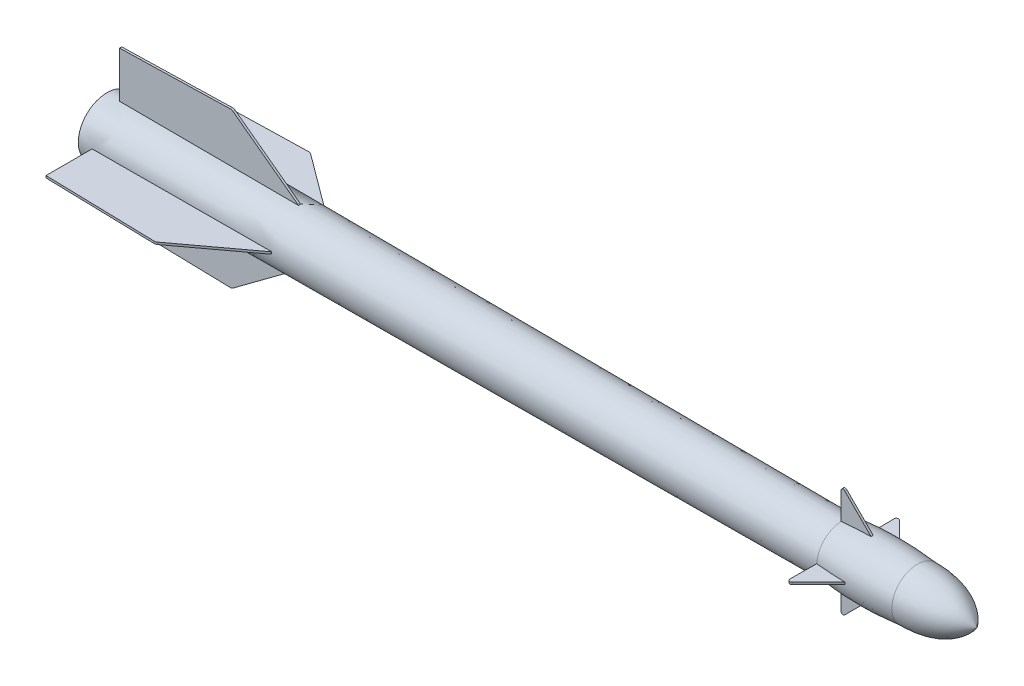
from build123d import *

# Parameters (mm, degrees)
BOSS_EXTRUDE8_DEPTH = 5
CIRPATTERN14_COUNT  = 4


with BuildPart() as part:
    # Sketch1 → Revolve2 (revolve)
    with BuildSketch(Plane.XY, mode=Mode.PRIVATE) as revolve2_sk:
        with BuildLine():
            Line((-11308.603422809, 18737.192157596), (-14752.957029779, 18751.87594239))
            Line((-14752.957029779, 18751.87594239), (-14752.957029779, 18617.692795252))
            Line((-14752.957029779, 18617.692795252), (-10678.442681077, 18617.692795252))
            add(Edge.make_bspline(
                [(-10678.442681077, 18617.692795252), (-10743.936723507, 18714.346501793), (-10855.803538483, 18738.002157903), (-10956.763854167, 18737.192157596)],
                knots=[0, 0, 0, 0, 1, 1, 1, 1], degree=3))
            add(Edge.make_bspline(
                [(-10956.763854167, 18737.192157596), (-11131.759366727, 18755.201630085), (-11308.603422809, 18737.192157596)],
                knots=[0, 0, 0, 1, 1, 1], degree=2))
        make_face()
    revolve(revolve2_sk.sketch.rotate(Axis((-10678.442681077, 18617.692795252, 0), (-1, 0, 0)), 90), axis=Axis((-10678.442681077, 18617.692795252, 0), (-1, 0, 0)))

    # Sketch3 (on Front Plane) → Boss-Extrude8 (add, symmetric)
    with BuildSketch(Plane.XY):
        with BuildLine():
            Line((-13854.314775163, 18751.130357924), (-14157.601672148, 18976.193937587))
            ThreePointArc((-14157.601672148, 18976.193937587), (-14163.477990114, 18979.198581722), (-14170.012281188, 18980.127042479))
            Line((-14170.012281188, 18980.127042479), (-14688.732210559, 18967.35855191))
            Line((-14688.732210559, 18967.35855191), (-14688.732210559, 18715.069519236))
            Line((-14688.732210559, 18715.069519236), (-13866.233225592, 18715.069519236))
            ThreePointArc((-13866.233225592, 18715.069519236), (-13847.243533997, 18728.793245411), (-13854.314775163, 18751.130357924))
        make_face()
        with BuildLine():
            Line((-11130.592643829, 18707.735714933), (-11292.671254125, 18869.814325229))
            ThreePointArc((-11292.671254125, 18869.814325229), (-11303.600882066, 18871.968847573), (-11309.742085757, 18862.674529378))
            Line((-11309.742085757, 18862.674529378), (-11308.671680106, 18706.933090059))
            ThreePointArc((-11308.671680106, 18706.933090059), (-11305.718643172, 18699.906492863), (-11298.671916286, 18697.001818098))
            Line((-11298.671916286, 18697.001818098), (-11127.663711641, 18697.001818098))
            Line((-11127.663711641, 18697.001818098), (-11127.663711641, 18700.664647121))
            ThreePointArc((-11127.663711641, 18700.664647121), (-11128.424916316, 18704.491481445), (-11130.592643829, 18707.735714933))
        make_face()
    boss_extrude8 = extrude(amount=BOSS_EXTRUDE8_DEPTH, both=True)

    # CirPattern14: Boss-Extrude8 ×4 about axis
    cirpattern14_axis = Axis((0, 18617.692795252, 0), (1, 0, 0))
    for i in range(1, CIRPATTERN14_COUNT):
        add(boss_extrude8.rotate(cirpattern14_axis, i * 360 / CIRPATTERN14_COUNT))


solid = part.part
